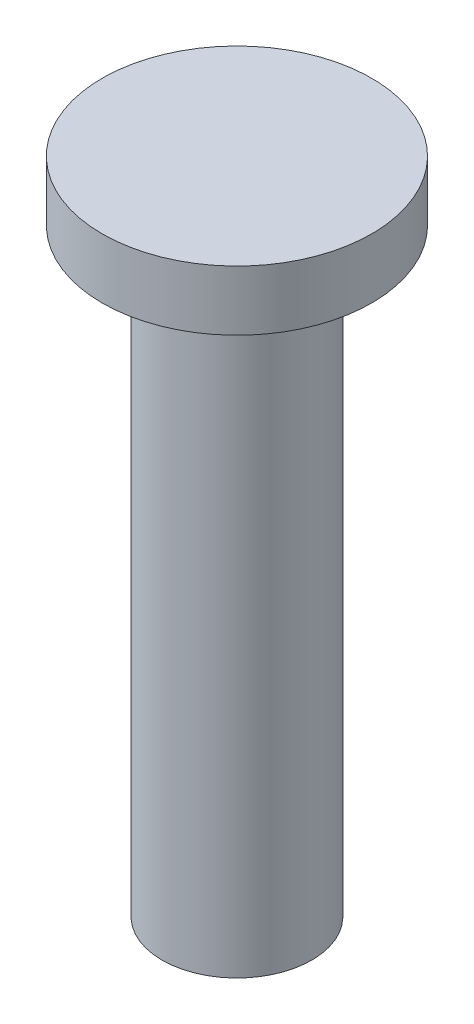
from build123d import *

# Parameters (mm, degrees)
SKETCH1_R           = 2.5
BOSS_EXTRUDE1_DEPTH = 20
SKETCH2_R           = 4.5
BOSS_EXTRUDE2_DEPTH = 2


with BuildPart() as part:
    # Sketch1 → Boss-Extrude1 (new body)
    with BuildSketch(Plane(origin=(0, 0, 0), x_dir=(1, 0, 0), z_dir=(0, 1, 0))):
        Circle(SKETCH1_R)
    extrude(amount=BOSS_EXTRUDE1_DEPTH)

    # Sketch2 → Boss-Extrude2 (add)
    with BuildSketch(Plane(origin=(0, 20, 0), x_dir=(1, 0, 0), z_dir=(0, 1, 0))):
        Circle(SKETCH2_R)
    extrude(amount=BOSS_EXTRUDE2_DEPTH)


solid = part.part
